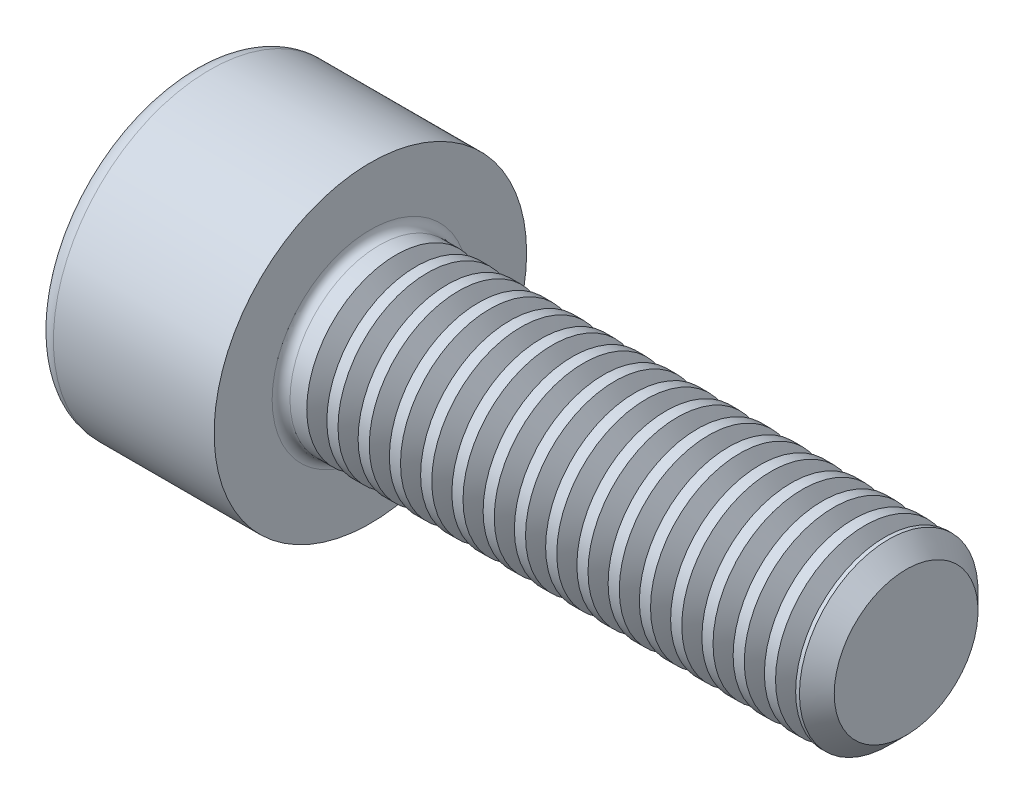
from build123d import *

# Parameters (mm, degrees)
BASEHEADSKE_R   = 3.5
BASEHEAD_DEPTH  = 4
CUTSOCKET_DEPTH = 2
FILLET1_R       = 0.2
FILLET2_R       = 0.4
THDSCHPAT_COUNT = 16
THDSCHPAT_PITCH = 0.7


with BuildPart() as part:
    # BaseHeadSke → BaseHead (new body)
    with BuildSketch(Plane(origin=(0, 0, 0), x_dir=(0, 0, -1), z_dir=(1, 0, 0))):
        Circle(BASEHEADSKE_R)
    extrude(amount=BASEHEAD_DEPTH)

    # BodySke → BaseBody (revolve)
    with BuildSketch(Plane.XY):
        Polygon((0, 0), (16, 0), (16, 1.61), (15.61, 2), (0, 2), align=None)
    revolve(axis=Axis((0, 0, 0), (1, 0, 0)))

    # CutSocketSke → CutSocket (cut)
    with BuildSketch(Plane(origin=(0, 0, 0), x_dir=(0, 0, -1), z_dir=(1, 0, 0))):
        Polygon((0, 1.732050808), (-1.5, 0.866025404), (-1.5, -0.866025404), (0, -1.732050808), (1.5, -0.866025404), (1.5, 0.866025404), align=None)
    extrude(amount=CUTSOCKET_DEPTH, mode=Mode.SUBTRACT)

    # CutHoleSke → CutHole (revolve, cut)
    with BuildSketch(Plane.XY):
        Polygon((0, 1.5), (2.6, 1.5), (3.466025404, 0), (0, 0), align=None)
    revolve(axis=Axis((0, 0, 0), (1, 0, 0)), mode=Mode.SUBTRACT)

    # Fillet1
    fillet1_edges = [part.edges().sort_by_distance(p)[0] for p in [
        (4, -2, 0),
    ]]
    fillet(fillet1_edges, radius=FILLET1_R)

    # Fillet2
    fillet2_edges = [part.edges().sort_by_distance(p)[0] for p in [
        (0, 0, 3.5),
    ]]
    fillet(fillet2_edges, radius=FILLET2_R)

    # ThdSchSke → ThreadSchematic (revolve, cut)
    with BuildSketch(Plane.XY):
        Polygon((15.074833395, 2.45033321), (15.074833395, 2), (15.3, 1.61), (15.525166605, 2), (15.525166605, 2.45033321), align=None)
    threadschematic = revolve(axis=Axis((0, 0, 0), (1, 0, 0)), mode=Mode.SUBTRACT)

    # ThdSchPat: ThreadSchematic ×16
    with Locations(*[(-i * THDSCHPAT_PITCH, 0, 0) for i in range(1, THDSCHPAT_COUNT)]):
        add(threadschematic, mode=Mode.SUBTRACT)


solid = part.part
